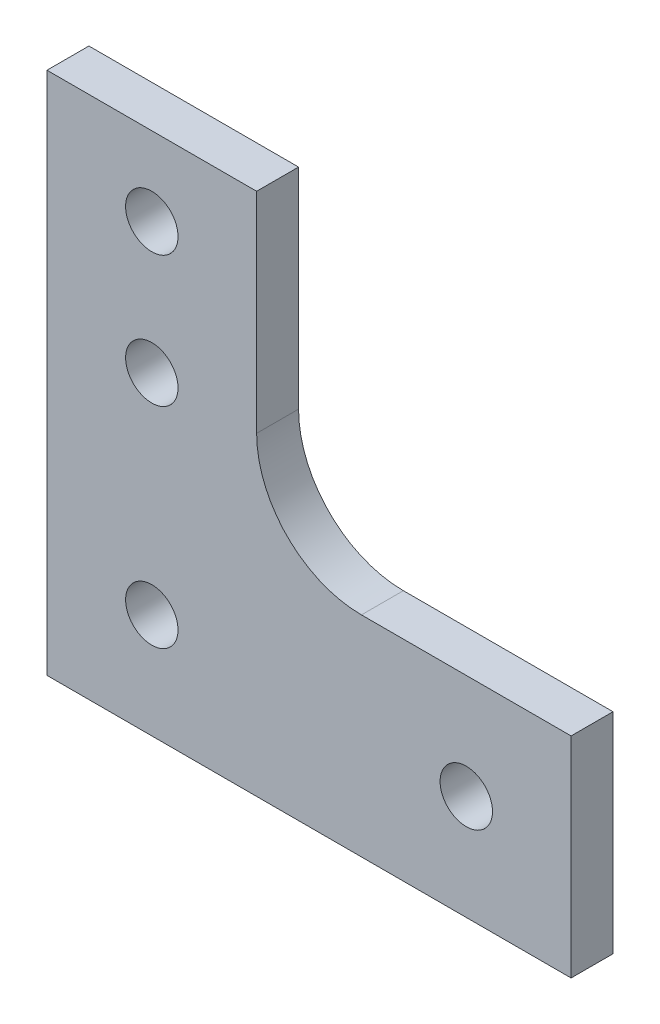
from build123d import *

# Parameters (mm, degrees)
SKETCH1_R           = 2.5
BOSS_EXTRUDE1_DEPTH = 4
FILLET1_R           = 10


with BuildPart() as part:
    # Sketch1 → Boss-Extrude1 (new body)
    with BuildSketch(Plane.XY):
        Polygon((-20, -10), (-20, 40), (0, 40), (0, 20), (0, 10), (10, 10), (30, 10), (30, -10), align=None)
        with Locations((-10, 32.5)):
            Circle(SKETCH1_R, mode=Mode.SUBTRACT)
        with Locations((-10, 0)):
            Circle(SKETCH1_R, mode=Mode.SUBTRACT)
        with Locations((20, 0)):
            Circle(SKETCH1_R, mode=Mode.SUBTRACT)
        with Locations((-10, 20)):
            Circle(SKETCH1_R, mode=Mode.SUBTRACT)
    extrude(amount=BOSS_EXTRUDE1_DEPTH)

    # Fillet1
    fillet1_edges = [part.edges().sort_by_distance(p)[0] for p in [
        (0, 10, 2),
    ]]
    fillet(fillet1_edges, radius=FILLET1_R)


solid = part.part
